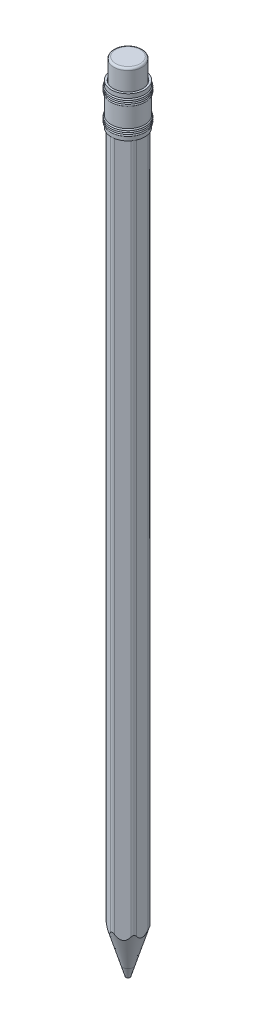
from build123d import *

# Parameters (mm, degrees)
SKETCH1_R           = 1.25
LEAD_DEPTH          = 185
SKETCH2_R           = 1.25
WOODEN_CASING_DEPTH = 185
SKETCH7_R           = 3.5
ERASER_DEPTH        = 10
FILLET1_R           = 0.5
FILLET2_R           = 1
SKETCH10_W          = 1.546794872
SKETCH10_H          = 0.189957265
SKETCH10_W_2        = 2.170940171
TEXT_2_DEPTH        = 0.1


with BuildPart() as part:
    # Sketch1 → lead (new body)
    with BuildSketch(Plane(origin=(0, 0, 0), x_dir=(1, 0, 0), z_dir=(0, 1, 0))):
        Circle(SKETCH1_R)
    extrude(amount=LEAD_DEPTH)


with BuildPart() as body_2:
    # Sketch2 → wooden casing (new body)
    with BuildSketch(Plane(origin=(0, 185, 0), x_dir=(1, 0, 0), z_dir=(0, 1, 0))):
        Polygon((3.5, 2.020725942), (0, 4.041451884), (-3.5, 2.020725942), (-3.5, -2.020725942), (0, -4.041451884), (3.5, -2.020725942), align=None)
        Circle(SKETCH2_R, mode=Mode.SUBTRACT)
    extrude(amount=-WOODEN_CASING_DEPTH)

    # Fillet2
    fillet2_edges = [body_2.edges().sort_by_distance(p)[0] for p in [
        (3.5, 92.5, 2.020725942),
        (0, 92.5, 4.041451884),
        (-3.5, 92.5, 2.020725942),
        (-3.5, 92.5, -2.020725942),
        (0, 92.5, -4.041451884),
        (3.5, 92.5, -2.020725942),
    ]]
    fillet(fillet2_edges, radius=FILLET2_R)

    # Sketch10 → text 2 (cut)
    with BuildSketch(Plane(origin=(-1.75, 0, -3.031088913), x_dir=(-0.866025404, 0, 0.5), z_dir=(-0.5, 0, -0.866025404))):
        with BuildLine():
            Line((-0.603419199, 151.264331842), (-0.603419199, 151.454289107))
            Line((-0.603419199, 151.454289107), (-0.317211266, 151.454289107))
            add(Edge.make_bspline(
                [(-0.317211266, 151.454289107), (-0.342978502, 151.47452059), (-0.393210927, 151.513961235), (-0.459049624, 151.580910418), (-0.513452039, 151.652841151), (-0.557314607, 151.729299821), (-0.589706716, 151.810771863), (-0.613813499, 151.896092609), (-0.627976406, 151.986233983), (-0.629684726, 152.04785591), (-0.630555951, 152.07928243)],
                knots=[0, 0, 0, 0, 9.8212e-05, 0.00019146, 0.000280758, 0.000368114, 0.00045504, 0.000543104, 0.000633658, 0.000727904, 0.000727904, 0.000727904, 0.000727904], degree=3))
            add(Edge.make_bspline(
                [(-0.630555951, 152.07928243), (-0.62976179, 152.106733542), (-0.62819209, 152.160992108), (-0.617564576, 152.240858918), (-0.599350543, 152.317769745), (-0.573103323, 152.391289473), (-0.540654539, 152.462205708), (-0.499701855, 152.529468597), (-0.452284778, 152.594125842), (-0.397715811, 152.654551347), (-0.338673954, 152.710383793), (-0.275160466, 152.758671722), (-0.209264044, 152.800322826), (-0.139963112, 152.8339901), (-0.067803388, 152.860362767), (0.007506669, 152.879119263), (0.085687833, 152.890281743), (0.13884805, 152.891779406), (0.16573812, 152.89253697)],
                knots=[0, 0, 0, 0, 8.2347e-05, 0.000162763, 0.000241232, 0.000319013, 0.000396602, 0.000474774, 0.00055483, 0.000636805, 0.0007187, 0.000798249, 0.000875779, 0.000952201, 0.001028927, 0.00110585, 0.001184643, 0.001265296, 0.001265296, 0.001265296, 0.001265296], degree=3))
            add(Edge.make_bspline(
                [(0.16573812, 152.89253697), (0.193195706, 152.891795843), (0.247346029, 152.890334234), (0.326864417, 152.878997969), (0.403359162, 152.860881192), (0.476703031, 152.834841244), (0.546845525, 152.801191391), (0.613736059, 152.760246252), (0.677353204, 152.71193396), (0.736833291, 152.656718516), (0.791624304, 152.596815074), (0.83954447, 152.532784402), (0.879786159, 152.465620194), (0.913400615, 152.395666074), (0.938735412, 152.322323188), (0.957009987, 152.24593373), (0.96827942, 152.166539289), (0.969762382, 152.112533354), (0.970512425, 152.085218594)],
                knots=[0, 0, 0, 0, 8.2347e-05, 0.0001624, 0.000240457, 0.000317838, 0.000395405, 0.000473434, 0.000552725, 0.000634643, 0.000716587, 0.000795962, 0.000874133, 0.000951135, 0.001028375, 0.001106433, 0.001186486, 0.001268409, 0.001268409, 0.001268409, 0.001268409], degree=3))
            add(Edge.make_bspline(
                [(0.970512425, 152.085218594), (0.969668335, 152.054491619), (0.968001643, 151.993819865), (0.953208674, 151.904859147), (0.92891304, 151.819628908), (0.894840696, 151.738379567), (0.851080577, 151.660884823), (0.797812227, 151.587450252), (0.735044883, 151.517712311), (0.687431544, 151.475736367), (0.663103905, 151.454289107)],
                knots=[0, 0, 0, 0, 9.2129e-05, 0.000181912, 0.000269684, 0.000357487, 0.00044558, 0.000536079, 0.000629147, 0.00072638, 0.00072638, 0.00072638, 0.00072638], degree=3))
            Line((0.663103905, 151.454289107), (1.513247468, 151.454289107))
            Line((1.513247468, 151.454289107), (1.513247468, 151.264331842))
            Line((1.513247468, 151.264331842), (-0.603419199, 151.264331842))
        make_face()
        with BuildLine():
            add(Edge.make_bspline(
                [(-0.440598686, 152.077586383), (-0.440211482, 152.056069219), (-0.439449178, 152.013707469), (-0.430393504, 151.951615222), (-0.417247346, 151.891807035), (-0.397343483, 151.834885665), (-0.37291182, 151.78030553), (-0.342382222, 151.728487011), (-0.306306962, 151.679466482), (-0.265377073, 151.633367278), (-0.220277142, 151.591721382), (-0.172145467, 151.554853325), (-0.121043002, 151.523885098), (-0.067445759, 151.498181495), (-0.01093361, 151.47862151), (0.048171593, 151.464738765), (0.109934543, 151.456011837), (0.151999366, 151.45486948), (0.173370331, 151.454289107)],
                knots=[0, 0, 0, 0, 6.45e-05, 0.000126984, 0.000187876, 0.000247949, 0.000307534, 0.00036702, 0.000427996, 0.000489864, 0.000551674, 0.000611885, 0.000671442, 0.000730615, 0.000789886, 0.000850462, 0.000912526, 0.00097662, 0.00097662, 0.00097662, 0.00097662], degree=3))
            add(Edge.make_bspline(
                [(0.173370331, 151.454289107), (0.201423023, 151.455255241), (0.256380623, 151.457147979), (0.336566282, 151.472388616), (0.412378509, 151.497470682), (0.483323938, 151.532932549), (0.548962684, 151.577229332), (0.607053567, 151.631569179), (0.658357544, 151.693931665), (0.701570104, 151.764142098), (0.736481279, 151.839477957), (0.762264157, 151.917796425), (0.777567444, 151.998547898), (0.779553862, 152.053070921), (0.78055516, 152.080554465)],
                knots=[0, 0, 0, 0, 8.4108e-05, 0.000164775, 0.000243885, 0.000322959, 0.00040199, 0.0004806, 0.000560733, 0.000643567, 0.000727228, 0.000809289, 0.000890373, 0.000972788, 0.000972788, 0.000972788, 0.000972788], degree=3))
            add(Edge.make_bspline(
                [(0.78055516, 152.080554465), (0.779613895, 152.107487969), (0.777745654, 152.160946134), (0.76157582, 152.239661272), (0.736872761, 152.316156213), (0.700859284, 152.388843366), (0.656695679, 152.457049385), (0.603754687, 152.518838067), (0.54197393, 152.572366401), (0.473639536, 152.618426198), (0.400430729, 152.65524914), (0.324821026, 152.683220316), (0.246824071, 152.699155721), (0.194214579, 152.701436884), (0.167858178, 152.702579706)],
                knots=[0, 0, 0, 0, 8.0723e-05, 0.00016022, 0.000240135, 0.000321297, 0.000402798, 0.000483374, 0.000564505, 0.000647296, 0.000729973, 0.000809779, 0.000888527, 0.000967586, 0.000967586, 0.000967586, 0.000967586], degree=3))
            add(Edge.make_bspline(
                [(0.167858178, 152.702579706), (0.141336803, 152.701699341), (0.088500682, 152.69994547), (0.010623041, 152.68269022), (-0.065483072, 152.656711401), (-0.137760663, 152.619065176), (-0.205587365, 152.573718404), (-0.266254431, 152.520087106), (-0.318368027, 152.458599723), (-0.362566644, 152.390923074), (-0.397070688, 152.317591099), (-0.422446265, 152.240628362), (-0.437658162, 152.160160018), (-0.439609889, 152.105353044), (-0.440598686, 152.077586383)],
                knots=[0, 0, 0, 0, 7.9453e-05, 0.000158288, 0.000238209, 0.00032013, 0.000401981, 0.000482476, 0.000562178, 0.000643092, 0.000724269, 0.000804586, 0.00088567, 0.000968932, 0.000968932, 0.000968932, 0.000968932], degree=3))
        make_face(mode=Mode.SUBTRACT)
        with BuildLine():
            Line((0.454914135, 154.541942686), (0.543532591, 154.710699364))
            add(Edge.make_bspline(
                [(0.543532591, 154.710699364), (0.56738076, 154.697244463), (0.613779854, 154.671066554), (0.677530207, 154.626231368), (0.734539621, 154.578800819), (0.783895211, 154.527331784), (0.827482326, 154.473375243), (0.86507865, 154.415906394), (0.897362557, 154.35539432), (0.923816206, 154.29117251), (0.944612927, 154.223317896), (0.959971447, 154.151436736), (0.96887793, 154.075189636), (0.969958909, 154.022975726), (0.970512425, 153.996239561)],
                knots=[0, 0, 0, 0, 8.2102e-05, 0.000159738, 0.000233463, 0.000304231, 0.000373298, 0.000441273, 0.000509938, 0.000578758, 0.000649305, 0.000722571, 0.000798989, 0.000879183, 0.000879183, 0.000879183, 0.000879183], degree=3))
            add(Edge.make_bspline(
                [(0.970512425, 153.996239561), (0.969818657, 153.966520365), (0.968465317, 153.908546824), (0.95679797, 153.8241585), (0.937764685, 153.744705235), (0.911176004, 153.670191482), (0.876446133, 153.600799771), (0.834137352, 153.536391992), (0.784466711, 153.476630156), (0.727005075, 153.423394765), (0.665509145, 153.375477401), (0.6014403, 153.333166093), (0.535020419, 153.297957019), (0.466644684, 153.26887887), (0.396468473, 153.24594172), (0.324089878, 153.229642228), (0.249795901, 153.220333038), (0.199542843, 153.218900106), (0.174218355, 153.218177996)],
                knots=[0, 0, 0, 0, 8.9124e-05, 0.000173856, 0.000254997, 0.000333861, 0.000410659, 0.000487218, 0.00056458, 0.00064317, 0.000721712, 0.000798272, 0.000873197, 0.000946912, 0.001020928, 0.001094375, 0.001169161, 0.001245135, 0.001245135, 0.001245135, 0.001245135], degree=3))
            add(Edge.make_bspline(
                [(0.174218355, 153.218177996), (0.150454338, 153.218818524), (0.103357196, 153.220087967), (0.033648985, 153.228089443), (-0.034101555, 153.242270078), (-0.099950721, 153.261729093), (-0.163788259, 153.286857703), (-0.225653022, 153.317599093), (-0.285479178, 153.35400115), (-0.323218216, 153.382106053), (-0.34222796, 153.396262932)],
                knots=[0, 0, 0, 0, 7.1296e-05, 0.000141299, 0.000210153, 0.000278708, 0.000347053, 0.000415697, 0.000485726, 0.000556803, 0.000556803, 0.000556803, 0.000556803], degree=3))
            add(Edge.make_bspline(
                [(-0.34222796, 153.396262932), (-0.365167582, 153.415405472), (-0.410246472, 153.453022677), (-0.468938508, 153.517306908), (-0.519144528, 153.585977489), (-0.560102698, 153.659725164), (-0.591606006, 153.738425709), (-0.614013893, 153.821673192), (-0.627957104, 153.909697707), (-0.629676498, 153.970039475), (-0.630555951, 154.000903691)],
                knots=[0, 0, 0, 0, 8.9548e-05, 0.000175971, 0.000260359, 0.00034425, 0.000428342, 0.000514024, 0.000602418, 0.00069497, 0.00069497, 0.00069497, 0.00069497], degree=3))
            add(Edge.make_bspline(
                [(-0.630555951, 154.000903691), (-0.629741175, 154.032623828), (-0.62814277, 154.094851507), (-0.613191755, 154.185559449), (-0.589770091, 154.271557745), (-0.555645838, 154.352136694), (-0.513346496, 154.428537899), (-0.459882109, 154.499002995), (-0.39799867, 154.565466295), (-0.350358063, 154.604111721), (-0.326115513, 154.623776954)],
                knots=[0, 0, 0, 0, 9.5093e-05, 0.000186551, 0.000275023, 0.00036188, 0.000448449, 0.000536305, 0.000626592, 0.000720137, 0.000720137, 0.000720137, 0.000720137], degree=3))
            add(Edge.make_bspline(
                [(-0.326115513, 154.623776954), (-0.307849538, 154.637158484), (-0.27143917, 154.663832471), (-0.212068995, 154.697243812), (-0.14995354, 154.726246618), (-0.084088741, 154.749428933), (-0.015254995, 154.76820044), (0.057039782, 154.781781469), (0.132774062, 154.789745953), (0.184376312, 154.791311498), (0.210683365, 154.79210962)],
                knots=[0, 0, 0, 0, 6.7875e-05, 0.000135298, 0.000203974, 0.000273311, 0.000344489, 0.000417837, 0.00049374, 0.000572679, 0.000572679, 0.000572679, 0.000572679], degree=3))
            Line((0.210683365, 154.79210962), (0.210683365, 153.408135261))
            add(Edge.make_bspline(
                [(0.210683365, 153.408135261), (0.231064122, 153.409066356), (0.271142059, 153.410897318), (0.329786294, 153.419433619), (0.385650173, 153.432888829), (0.438314679, 153.451799167), (0.488467661, 153.474699593), (0.535737083, 153.502751907), (0.579907641, 153.536219161), (0.621374434, 153.573548513), (0.658301656, 153.615099947), (0.691352968, 153.658813799), (0.719054448, 153.705316097), (0.741539429, 153.754240176), (0.75914182, 153.805506923), (0.771157121, 153.859132488), (0.779204753, 153.915011349), (0.780099598, 153.953102722), (0.78055516, 153.972494903)],
                knots=[0, 0, 0, 0, 6.1177e-05, 0.000120302, 0.000177481, 0.00023327, 0.000287908, 0.000342665, 0.000397786, 0.000453918, 0.000509765, 0.000564293, 0.000618104, 0.000671795, 0.000725564, 0.000780387, 0.000836454, 0.000894599, 0.000894599, 0.000894599, 0.000894599], degree=3))
            add(Edge.make_bspline(
                [(0.78055516, 153.972494903), (0.780190392, 153.99145571), (0.779466622, 154.029077589), (0.772327988, 154.085091064), (0.761013874, 154.140294226), (0.744718108, 154.194138924), (0.725635985, 154.245840439), (0.703176451, 154.293983368), (0.677570039, 154.337931238), (0.64847156, 154.379166527), (0.612760083, 154.418946196), (0.568623819, 154.459032543), (0.515562174, 154.501066957), (0.475890895, 154.527804712), (0.454914135, 154.541942686)],
                knots=[0, 0, 0, 0, 5.6857e-05, 0.000112815, 0.000169113, 0.000225728, 0.000281409, 0.000334331, 0.000384874, 0.000433819, 0.000485476, 0.000544889, 0.0006125, 0.000688365, 0.000688365, 0.000688365, 0.000688365], degree=3))
        make_face()
        with BuildLine():
            add(Edge.make_bspline(
                [(0.0207261, 154.602152355), (-0.00448261, 154.59522779), (-0.052875143, 154.581934875), (-0.119863688, 154.553625302), (-0.179742238, 154.522511482), (-0.231515746, 154.485056565), (-0.277571164, 154.443033584), (-0.317174949, 154.393823658), (-0.353676999, 154.339561078), (-0.384074516, 154.279165041), (-0.409053959, 154.215017268), (-0.427421571, 154.148436247), (-0.438218603, 154.079979657), (-0.439801596, 154.033872484), (-0.440598686, 154.010655961)],
                knots=[0, 0, 0, 0, 7.8342e-05, 0.000150392, 0.000217735, 0.000280334, 0.000341545, 0.000404195, 0.000469345, 0.000537423, 0.000606558, 0.000675579, 0.000744244, 0.000813887, 0.000813887, 0.000813887, 0.000813887], degree=3))
            add(Edge.make_bspline(
                [(-0.440598686, 154.010655961), (-0.440233084, 153.991695566), (-0.439510366, 153.954214851), (-0.432511344, 153.899020376), (-0.421264693, 153.845876722), (-0.404728225, 153.794942522), (-0.384606612, 153.74587991), (-0.359873078, 153.698724338), (-0.329969802, 153.654081999), (-0.307126846, 153.6261806), (-0.295586667, 153.612084914)],
                knots=[0, 0, 0, 0, 5.6857e-05, 0.000112395, 0.000166618, 0.000219586, 0.000272816, 0.000325544, 0.000379051, 0.000433683, 0.000433683, 0.000433683, 0.000433683], degree=3))
            add(Edge.make_bspline(
                [(-0.295586667, 153.612084914), (-0.286459159, 153.601987871), (-0.267987308, 153.581553916), (-0.236144194, 153.554279343), (-0.201787338, 153.52797015), (-0.163417032, 153.504590599), (-0.122145973, 153.482371806), (-0.077673017, 153.462124724), (-0.029810442, 153.443715141), (0.003558332, 153.433380726), (0.0207261, 153.428063813)],
                knots=[0, 0, 0, 0, 4.0793e-05, 8.2556e-05, 0.000125551, 0.000170496, 0.000217162, 0.000266115, 0.000316984, 0.000370889, 0.000370889, 0.000370889, 0.000370889], degree=3))
            Line((0.0207261, 153.428063813), (0.0207261, 154.602152355))
        make_face(mode=Mode.SUBTRACT)
        with BuildLine():
            Line((-0.603419199, 155.17202415), (-0.603419199, 155.361981415))
            Line((-0.603419199, 155.361981415), (-0.324419466, 155.361981415))
            add(Edge.make_bspline(
                [(-0.324419466, 155.361981415), (-0.349762188, 155.382228687), (-0.398863381, 155.421457513), (-0.46289085, 155.487459193), (-0.516620138, 155.556279309), (-0.558924228, 155.629035607), (-0.590918916, 155.704979409), (-0.613990856, 155.783895227), (-0.627833243, 155.866210194), (-0.629641277, 155.922189915), (-0.630555951, 155.950509727)],
                knots=[0, 0, 0, 0, 9.7232e-05, 0.000188386, 0.000275146, 0.000358561, 0.00044007, 0.000521786, 0.000604737, 0.000689668, 0.000689668, 0.000689668, 0.000689668], degree=3))
            add(Edge.make_bspline(
                [(-0.630555951, 155.950509727), (-0.629561726, 155.979147931), (-0.627614813, 156.035227901), (-0.610410434, 156.116572987), (-0.583343217, 156.193011697), (-0.54491073, 156.263417337), (-0.497448, 156.32703464), (-0.442070067, 156.38270618), (-0.378706573, 156.429128597), (-0.31957811, 156.460157833), (-0.267033951, 156.480209158), (-0.222095045, 156.493389038), (-0.172006279, 156.504050987), (-0.116892771, 156.513604791), (-0.056532768, 156.519978157), (0.008929549, 156.525030258), (0.079482882, 156.528643879), (0.128279006, 156.528787629), (0.153441779, 156.528861757)],
                knots=[0, 0, 0, 0, 8.5828e-05, 0.000168069, 0.000248274, 0.000328339, 0.000407714, 0.000485668, 0.000563011, 0.000642478, 0.000685158, 0.000731579, 0.000782813, 0.000838718, 0.000899309, 0.000964805, 0.001035696, 0.001111175, 0.001111175, 0.001111175, 0.001111175], degree=3))
            Line((0.153441779, 156.528861757), (0.943375673, 156.528861757))
            Line((0.943375673, 156.528861757), (0.943375673, 156.338904492))
            Line((0.943375673, 156.338904492), (0.215771506, 156.338904492))
            add(Edge.make_bspline(
                [(0.215771506, 156.338904492), (0.194712188, 156.338788131), (0.154429296, 156.338565551), (0.096754136, 156.337854337), (0.044590127, 156.336180173), (-0.002212648, 156.333730943), (-0.043482886, 156.33030264), (-0.07942949, 156.326632579), (-0.109734052, 156.322181335), (-0.127976721, 156.318212033), (-0.136158248, 156.316431869)],
                knots=[0, 0, 0, 0, 6.3179e-05, 0.000120851, 0.000173032, 0.000219743, 0.000261434, 0.000297255, 0.000328138, 0.000353251, 0.000353251, 0.000353251, 0.000353251], degree=3))
            add(Edge.make_bspline(
                [(-0.136158248, 156.316431869), (-0.160191313, 156.310037849), (-0.206324508, 156.29776407), (-0.268793601, 156.266818393), (-0.322409558, 156.228647232), (-0.366069699, 156.181354038), (-0.400057995, 156.126208991), (-0.423622777, 156.063120416), (-0.438366118, 155.992741248), (-0.439833737, 155.943238516), (-0.440598686, 155.91743681)],
                knots=[0, 0, 0, 0, 7.4444e-05, 0.000142901, 0.000207867, 0.000270875, 0.000334653, 0.000400957, 0.000471973, 0.000549284, 0.000549284, 0.000549284, 0.000549284], degree=3))
            add(Edge.make_bspline(
                [(-0.440598686, 155.91743681), (-0.440314957, 155.90215452), (-0.439753466, 155.871911261), (-0.4339773, 155.827087987), (-0.424846158, 155.783476056), (-0.411389424, 155.741174755), (-0.394872474, 155.700046794), (-0.375002014, 155.659803504), (-0.350540889, 155.621373583), (-0.323194572, 155.584124646), (-0.292913078, 155.549462309), (-0.260953566, 155.517211811), (-0.226920529, 155.48846251), (-0.191360481, 155.462416246), (-0.153785533, 155.439932241), (-0.114558066, 155.420305852), (-0.073626482, 155.403653312), (-0.045217755, 155.395378541), (-0.031003333, 155.391238226)],
                knots=[0, 0, 0, 0, 4.5825e-05, 9.0686e-05, 0.000135344, 0.000179331, 0.00022366, 0.000268222, 0.000313751, 0.000360139, 0.000406729, 0.000451702, 0.000496221, 0.000540239, 0.000583796, 0.00062741, 0.000671739, 0.000716131, 0.000716131, 0.000716131, 0.000716131], degree=3))
            add(Edge.make_bspline(
                [(-0.031003333, 155.391238226), (-0.020568044, 155.388855676), (0.002149035, 155.383668991), (0.039429232, 155.378066973), (0.082554788, 155.372982391), (0.13147538, 155.368726707), (0.186362285, 155.366122955), (0.246981101, 155.363283963), (0.313573544, 155.362250388), (0.359935616, 155.362073583), (0.384104172, 155.361981415)],
                knots=[0, 0, 0, 0, 3.2102e-05, 6.9884e-05, 0.000113011, 0.000162378, 0.000217156, 0.000277843, 0.000344425, 0.000416933, 0.000416933, 0.000416933, 0.000416933], degree=3))
            Line((0.384104172, 155.361981415), (0.943375673, 155.361981415))
            Line((0.943375673, 155.361981415), (0.943375673, 155.17202415))
            Line((0.943375673, 155.17202415), (-0.603419199, 155.17202415))
        make_face()
        with BuildLine():
            Line((-0.268025903, 158.482707911), (-0.169231165, 158.323703504))
            add(Edge.make_bspline(
                [(-0.169231165, 158.323703504), (-0.190898812, 158.306268299), (-0.233547898, 158.27195006), (-0.288587239, 158.212357284), (-0.335859688, 158.148850381), (-0.37438529, 158.080344133), (-0.404152548, 158.006934625), (-0.425216529, 157.928911358), (-0.438342428, 157.846285457), (-0.439834277, 157.789640313), (-0.440598686, 157.760615897)],
                knots=[0, 0, 0, 0, 8.3336e-05, 0.000164034, 0.000242563, 0.000320401, 0.000399139, 0.000479578, 0.000562395, 0.00064942, 0.00064942, 0.00064942, 0.00064942], degree=3))
            add(Edge.make_bspline(
                [(-0.440598686, 157.760615897), (-0.439959548, 157.737417861), (-0.438700783, 157.69172996), (-0.430832533, 157.624658143), (-0.416534747, 157.560769673), (-0.397695835, 157.499664101), (-0.37244685, 157.441776039), (-0.341719045, 157.386953816), (-0.30600783, 157.334711163), (-0.264635738, 157.286561991), (-0.219642258, 157.242517782), (-0.171410262, 157.204357962), (-0.121384423, 157.171134198), (-0.068315512, 157.145065358), (-0.013417613, 157.123732278), (0.044345528, 157.109697738), (0.104233895, 157.100345279), (0.145066414, 157.099275257), (0.16573812, 157.098733552)],
                knots=[0, 0, 0, 0, 6.9601e-05, 0.000137078, 0.0002022, 0.000265765, 0.000328624, 0.000391264, 0.000454069, 0.000518135, 0.000581403, 0.000642656, 0.0007024, 0.000761183, 0.000819694, 0.000878723, 0.000939168, 0.001001145, 0.001001145, 0.001001145, 0.001001145], degree=3))
            add(Edge.make_bspline(
                [(0.16573812, 157.098733552), (0.192808964, 157.099825884), (0.246724424, 157.102001419), (0.326175482, 157.118548052), (0.402849842, 157.146234928), (0.47633299, 157.183638613), (0.54441973, 157.231116423), (0.605492244, 157.286854152), (0.658357708, 157.350911242), (0.702186446, 157.422715685), (0.73742067, 157.500583559), (0.762522733, 157.583671834), (0.777673451, 157.671301708), (0.779582045, 157.731298169), (0.78055516, 157.761887932)],
                knots=[0, 0, 0, 0, 8.1174e-05, 0.000161669, 0.000242272, 0.000325141, 0.000408301, 0.000490531, 0.000572454, 0.000656593, 0.000742182, 0.00082816, 0.00091634, 0.001008068, 0.001008068, 0.001008068, 0.001008068], degree=3))
            add(Edge.make_bspline(
                [(0.78055516, 157.761887932), (0.779769274, 157.789921782), (0.778224798, 157.845015735), (0.765204902, 157.925550236), (0.743890895, 158.002221897), (0.714168268, 158.075027991), (0.675749247, 158.143835482), (0.628360605, 158.208199793), (0.573365614, 158.26940166), (0.530839983, 158.305383165), (0.509187639, 158.323703504)],
                knots=[0, 0, 0, 0, 8.4061e-05, 0.000165203, 0.000244006, 0.000322352, 0.00040056, 0.000479773, 0.000561717, 0.00064672, 0.00064672, 0.00064672, 0.00064672], degree=3))
            Line((0.509187639, 158.323703504), (0.61349453, 158.482707911))
            add(Edge.make_bspline(
                [(0.61349453, 158.482707911), (0.627337969, 158.473281062), (0.654978901, 158.454458654), (0.693952247, 158.422994328), (0.730432503, 158.389055192), (0.764370767, 158.352773652), (0.796579188, 158.314623451), (0.825517998, 158.273301334), (0.852813819, 158.230139712), (0.877374937, 158.184631888), (0.89945257, 158.137248371), (0.918436754, 158.088055834), (0.934747246, 158.037268043), (0.947711737, 157.984825282), (0.95805972, 157.930624163), (0.964926007, 157.87480486), (0.970051534, 157.817386599), (0.970357463, 157.778577726), (0.970512425, 157.75891985)],
                knots=[0, 0, 0, 0, 5.0229e-05, 0.000100291, 0.000150094, 0.000199587, 0.000249262, 0.000299735, 0.000350793, 0.000402399, 0.000454757, 0.000507514, 0.000560481, 0.000614677, 0.000669479, 0.000725911, 0.000783342, 0.000842294, 0.000842294, 0.000842294, 0.000842294], degree=3))
            add(Edge.make_bspline(
                [(0.970512425, 157.75891985), (0.969972518, 157.72891747), (0.968914295, 157.670112587), (0.957310374, 157.584035819), (0.939752034, 157.501800043), (0.914764782, 157.423260742), (0.881766248, 157.348898076), (0.842381322, 157.278092972), (0.795308446, 157.211576093), (0.741665914, 157.149783502), (0.683445631, 157.093274197), (0.620984012, 157.044102215), (0.555661275, 157.002430496), (0.487065678, 156.968102696), (0.415478492, 156.941261559), (0.340462387, 156.922782392), (0.262653836, 156.910859006), (0.209596959, 156.909476951), (0.18269859, 156.908776287)],
                knots=[0, 0, 0, 0, 8.9954e-05, 0.000176311, 0.000260061, 0.000341992, 0.000423059, 0.000503738, 0.000584675, 0.000667044, 0.000748909, 0.000827713, 0.000905111, 0.00098096, 0.001057436, 0.001133947, 0.001212381, 0.001293034, 0.001293034, 0.001293034, 0.001293034], degree=3))
            add(Edge.make_bspline(
                [(0.18269859, 156.908776287), (0.164447822, 156.909042996), (0.128144033, 156.909573526), (0.074262731, 156.915658597), (0.021098992, 156.923519578), (-0.030673296, 156.936839905), (-0.081839352, 156.95222543), (-0.131782466, 156.971865394), (-0.18073472, 156.994904038), (-0.228570014, 157.021061168), (-0.274501402, 157.050506266), (-0.317895285, 157.083091583), (-0.359272953, 157.117589825), (-0.397205894, 157.155614902), (-0.433211114, 157.195553169), (-0.466326742, 157.23853455), (-0.496650103, 157.284312518), (-0.524741908, 157.332199575), (-0.549754518, 157.382167852), (-0.571304143, 157.433915315), (-0.589720701, 157.487130147), (-0.604300857, 157.541897472), (-0.616527584, 157.597853777), (-0.624218853, 157.655440015), (-0.629653409, 157.714435882), (-0.630252602, 157.754384049), (-0.630555951, 157.774608285)],
                knots=[0, 0, 0, 0, 5.4724e-05, 0.000108855, 0.00016253, 0.000215801, 0.000269046, 0.000322747, 0.000376616, 0.000431268, 0.000486195, 0.000540129, 0.000593985, 0.000647654, 0.000701107, 0.000755216, 0.000810253, 0.00086574, 0.000921679, 0.000977746, 0.001033796, 0.001090471, 0.001147686, 0.001205492, 0.001264649, 0.001325306, 0.001325306, 0.001325306, 0.001325306], degree=3))
            add(Edge.make_bspline(
                [(-0.630555951, 157.774608285), (-0.629998484, 157.79993581), (-0.628886337, 157.850464262), (-0.61952458, 157.925418412), (-0.605414829, 157.999270788), (-0.584494532, 158.070715129), (-0.559219998, 158.138923383), (-0.530666918, 158.20260212), (-0.498212122, 158.260789662), (-0.462054308, 158.313999258), (-0.420864787, 158.362216163), (-0.375062815, 158.406676191), (-0.32431871, 158.447672272), (-0.286945032, 158.470932982), (-0.268025903, 158.482707911)],
                knots=[0, 0, 0, 0, 7.5956e-05, 0.000151533, 0.00022629, 0.000301306, 0.000374556, 0.000444388, 0.000510447, 0.000574191, 0.000637061, 0.00070033, 0.00076549, 0.00083229, 0.00083229, 0.00083229, 0.00083229], degree=3))
        make_face()
        with BuildLine():
            add(Edge.make_bspline(
                [(-1.25470125, 158.929616297), (-1.254154453, 158.941403903), (-1.25308372, 158.964486298), (-1.243914636, 158.997865083), (-1.228372445, 159.02825861), (-1.207520448, 159.055217524), (-1.182997689, 159.078350808), (-1.154416056, 159.094546762), (-1.123537736, 159.104956163), (-1.101999087, 159.106213194), (-1.091032714, 159.10685321)],
                knots=[0, 0, 0, 0, 3.5318e-05, 6.9159e-05, 0.000102913, 0.00013709, 0.000171003, 0.000203295, 0.00023494, 0.000267764, 0.000267764, 0.000267764, 0.000267764], degree=3))
            add(Edge.make_bspline(
                [(-1.091032714, 159.10685321), (-1.080351014, 159.106198761), (-1.059234558, 159.104904992), (-1.028891553, 159.094554802), (-1.000707058, 159.078212782), (-0.976231914, 159.055232358), (-0.955391444, 159.028254679), (-0.939846197, 158.997866128), (-0.930677924, 158.964486023), (-0.929607078, 158.94140381), (-0.929060224, 158.929616297)],
                knots=[0, 0, 0, 0, 3.1981e-05, 6.3223e-05, 9.5148e-05, 0.000129061, 0.000163238, 0.000196992, 0.000230833, 0.000266151, 0.000266151, 0.000266151, 0.000266151], degree=3))
            add(Edge.make_bspline(
                [(-0.929060224, 158.929616297), (-0.929586198, 158.917963579), (-0.930609937, 158.895283084), (-0.940026091, 158.862404089), (-0.955396763, 158.832269717), (-0.976095456, 158.805258224), (-1.00085737, 158.782742822), (-1.028874353, 158.766354787), (-1.059238937, 158.7560285), (-1.080352485, 158.754731511), (-1.091032714, 158.754075432)],
                knots=[0, 0, 0, 0, 3.4895e-05, 6.7919e-05, 0.000101673, 0.00013585, 0.000169478, 0.000201403, 0.000232645, 0.000264626, 0.000264626, 0.000264626, 0.000264626], degree=3))
            add(Edge.make_bspline(
                [(-1.091032714, 158.754075432), (-1.101997561, 158.754717137), (-1.123533213, 158.755977485), (-1.154433542, 158.766362527), (-1.182846164, 158.782606316), (-1.207656824, 158.805273133), (-1.228367158, 158.832265749), (-1.243734752, 158.862405114), (-1.253151704, 158.895282813), (-1.254175333, 158.917963487), (-1.25470125, 158.929616297)],
                knots=[0, 0, 0, 0, 3.2825e-05, 6.447e-05, 9.6761e-05, 0.00013039, 0.000164567, 0.00019832, 0.000231344, 0.00026624, 0.00026624, 0.00026624, 0.00026624], degree=3))
        make_face()
        with Locations((0.169978237, 158.93046432)):
            Rectangle(SKETCH10_W, SKETCH10_H)
        with Locations((-0.142094412, 159.527472868)):
            Rectangle(SKETCH10_W_2, SKETCH10_H)
        with BuildLine():
            Line((-0.522008942, 161.006425859), (-0.522008942, 160.816468594))
            add(Edge.make_bspline(
                [(-0.522008942, 160.816468594), (-0.547209908, 160.817706635), (-0.596703933, 160.820138112), (-0.668866486, 160.831524745), (-0.737842484, 160.847817561), (-0.803078098, 160.870853821), (-0.865150139, 160.899462856), (-0.923812053, 160.933771015), (-0.978840058, 160.974407296), (-1.029724025, 161.020494226), (-1.076404127, 161.070549546), (-1.116714679, 161.124558376), (-1.150773461, 161.181312273), (-1.179246402, 161.240639052), (-1.200618595, 161.30320806), (-1.216476444, 161.368451503), (-1.226017377, 161.436656028), (-1.227042923, 161.483125946), (-1.227564498, 161.506759727)],
                knots=[0, 0, 0, 0, 7.5645e-05, 0.000148566, 0.000218806, 0.000288002, 0.000355729, 0.000423578, 0.000491507, 0.00056056, 0.000629272, 0.00069652, 0.00076233, 0.000827574, 0.000893548, 0.000960292, 0.001028772, 0.001099644, 0.001099644, 0.001099644, 0.001099644], degree=3))
            add(Edge.make_bspline(
                [(-1.227564498, 161.506759727), (-1.227025555, 161.529970957), (-1.225966552, 161.575580196), (-1.216735362, 161.642118404), (-1.202589386, 161.705611811), (-1.181627278, 161.765340849), (-1.155324418, 161.821918504), (-1.122613366, 161.874644253), (-1.085041898, 161.924793057), (-1.04072451, 161.969903702), (-0.993437744, 162.011343271), (-0.942935876, 162.047061674), (-0.890715389, 162.077822644), (-0.836368366, 162.102999537), (-0.779717826, 162.122084742), (-0.721306898, 162.136225049), (-0.660461479, 162.144308413), (-0.619272044, 162.145542189), (-0.598331058, 162.146169449)],
                knots=[0, 0, 0, 0, 6.9601e-05, 0.000136764, 0.000201152, 0.000264445, 0.000326281, 0.000387948, 0.000450279, 0.000513853, 0.000577275, 0.000638691, 0.000699123, 0.000758884, 0.000818017, 0.00087818, 0.000938926, 0.00100175, 0.00100175, 0.00100175, 0.00100175], degree=3))
            add(Edge.make_bspline(
                [(-0.598331058, 162.146169449), (-0.568850237, 162.145145412), (-0.510405943, 162.143115309), (-0.424520578, 162.125750183), (-0.341310028, 162.098627824), (-0.274338043, 162.065975174), (-0.220378135, 162.033025837), (-0.175928276, 162.003363399), (-0.128080324, 161.968441126), (-0.076640613, 161.928557378), (-0.022282791, 161.883025302), (0.036102188, 161.833027813), (0.097434747, 161.77727371), (0.139353001, 161.738176681), (0.16107399, 161.717917579)],
                knots=[0, 0, 0, 0, 8.8367e-05, 0.000175182, 0.000261801, 0.000350363, 0.00039792, 0.000451428, 0.000510628, 0.000575595, 0.00064666, 0.000723327, 0.000806184, 0.000895292, 0.000895292, 0.000895292, 0.000895292], degree=3))
            Line((0.16107399, 161.717917579), (0.726281656, 161.188326901))
            Line((0.726281656, 161.188326901), (0.726281656, 162.173306201))
            Line((0.726281656, 162.173306201), (0.943375673, 162.173306201))
            Line((0.943375673, 162.173306201), (0.943375673, 160.735058338))
            Line((0.943375673, 160.735058338), (0.067367393, 161.55594509))
            add(Edge.make_bspline(
                [(0.067367393, 161.55594509), (0.046504131, 161.575931193), (0.006430076, 161.614320407), (-0.052076381, 161.668617489), (-0.106353484, 161.717384877), (-0.156298683, 161.760938253), (-0.202642536, 161.798332801), (-0.243884094, 161.831517437), (-0.281835595, 161.858106151), (-0.325826347, 161.886962605), (-0.379536654, 161.91491106), (-0.445173694, 161.93892758), (-0.51274208, 161.953571798), (-0.558402836, 161.955328532), (-0.581370588, 161.956212184)],
                knots=[0, 0, 0, 0, 8.6674e-05, 0.000166483, 0.000239444, 0.000305579, 0.000365245, 0.00041809, 0.000464325, 0.000504196, 0.000575883, 0.000645364, 0.000713388, 0.000782236, 0.000782236, 0.000782236, 0.000782236], degree=3))
            add(Edge.make_bspline(
                [(-0.581370588, 161.956212184), (-0.595813148, 161.955827711), (-0.62427666, 161.95506999), (-0.666008714, 161.948382715), (-0.706264578, 161.938276838), (-0.745168076, 161.923795658), (-0.782328066, 161.904681106), (-0.81778978, 161.881413871), (-0.852073107, 161.854568452), (-0.884218196, 161.82351316), (-0.913658735, 161.789397622), (-0.939738539, 161.75335729), (-0.96153362, 161.715226989), (-0.979400402, 161.675167487), (-0.993415989, 161.633290465), (-1.003127607, 161.589514928), (-1.009225109, 161.543961833), (-1.010050108, 161.512856814), (-1.010470481, 161.497007457)],
                knots=[0, 0, 0, 0, 4.3301e-05, 8.5338e-05, 0.000126474, 0.000167664, 0.000209573, 0.000251559, 0.000294735, 0.000340017, 0.00038541, 0.000429771, 0.000473265, 0.00051692, 0.000561168, 0.000605503, 0.000651259, 0.000698795, 0.000698795, 0.000698795, 0.000698795], degree=3))
            add(Edge.make_bspline(
                [(-1.010470481, 161.497007457), (-1.010055119, 161.480450465), (-1.009239418, 161.447935267), (-1.003060889, 161.400297089), (-0.993694236, 161.354538542), (-0.978817946, 161.311342383), (-0.961240871, 161.269773227), (-0.938911091, 161.23071851), (-0.91296339, 161.193529804), (-0.882875973, 161.158818792), (-0.849070586, 161.12711659), (-0.811814715, 161.098870387), (-0.771376573, 161.074352685), (-0.727922126, 161.052931342), (-0.681018731, 161.035543014), (-0.630843541, 161.022253918), (-0.577611418, 161.011739175), (-0.540850934, 161.008226381), (-0.522008942, 161.006425859)],
                knots=[0, 0, 0, 0, 4.9655e-05, 9.7514e-05, 0.000143919, 0.000189508, 0.000234327, 0.000279136, 0.000324189, 0.00037018, 0.000416677, 0.000462979, 0.000510174, 0.00055834, 0.000608116, 0.000659957, 0.000713926, 0.000770677, 0.000770677, 0.000770677, 0.000770677], degree=3))
        make_face()
        with BuildLine():
            Line((0.943375673, 162.498947227), (-1.227564498, 162.498947227))
            Line((-1.227564498, 162.498947227), (-1.227564498, 162.688904492))
            Line((-1.227564498, 162.688904492), (-0.322723419, 162.688904492))
            add(Edge.make_bspline(
                [(-0.322723419, 162.688904492), (-0.347372263, 162.710309083), (-0.395463175, 162.752070324), (-0.458266278, 162.822087511), (-0.511517062, 162.895508974), (-0.555414381, 162.972893253), (-0.588841753, 163.054350408), (-0.613287674, 163.139459826), (-0.628035944, 163.228439074), (-0.62970876, 163.289108289), (-0.630555951, 163.319833979)],
                knots=[0, 0, 0, 0, 9.7859e-05, 0.000190928, 0.000281426, 0.00036952, 0.00045716, 0.000544932, 0.000634715, 0.000726844, 0.000726844, 0.000726844, 0.000726844], degree=3))
            add(Edge.make_bspline(
                [(-0.630555951, 163.319833979), (-0.629805908, 163.347148739), (-0.628322946, 163.401154673), (-0.617053513, 163.480549115), (-0.598778937, 163.556938572), (-0.573444143, 163.630281463), (-0.539829676, 163.700235563), (-0.499588028, 163.767399849), (-0.451667705, 163.831430216), (-0.396877298, 163.891334837), (-0.33739496, 163.946545902), (-0.273785912, 163.994873944), (-0.206974786, 164.035695189), (-0.137185224, 164.069459827), (-0.064132193, 164.095568036), (0.01211268, 164.113555026), (0.091474386, 164.124981073), (0.145487367, 164.126420556), (0.172946319, 164.127152355)],
                knots=[0, 0, 0, 0, 8.1923e-05, 0.000161976, 0.000240033, 0.000317273, 0.000394276, 0.000472447, 0.000551822, 0.000633766, 0.000715684, 0.000794975, 0.000873004, 0.000950189, 0.00102717, 0.001105228, 0.00118486, 0.001267207, 0.001267207, 0.001267207, 0.001267207], degree=3))
            add(Edge.make_bspline(
                [(0.172946319, 164.127152355), (0.199979187, 164.126404603), (0.253283745, 164.124930154), (0.331725329, 164.113668696), (0.407223019, 164.095074526), (0.479581727, 164.068488477), (0.549141389, 164.035066348), (0.615109062, 163.993270481), (0.678632633, 163.945003829), (0.737671686, 163.889165468), (0.792241409, 163.828741557), (0.839658289, 163.764083896), (0.880611024, 163.696821115), (0.913059794, 163.625904852), (0.939307018, 163.552385131), (0.95752105, 163.475474302), (0.968148565, 163.395607493), (0.969718265, 163.341348927), (0.970512425, 163.313897814)],
                knots=[0, 0, 0, 0, 8.1076e-05, 0.000159869, 0.000237204, 0.00031393, 0.000390733, 0.000468264, 0.000547812, 0.000629708, 0.000711682, 0.000791739, 0.00086991, 0.000947499, 0.00102528, 0.00110375, 0.001184166, 0.001266512, 0.001266512, 0.001266512, 0.001266512], degree=3))
            add(Edge.make_bspline(
                [(0.970512425, 163.313897814), (0.969642163, 163.2824707), (0.967935729, 163.220847607), (0.953759218, 163.130714639), (0.929702123, 163.04536319), (0.897153346, 162.964068863), (0.853983909, 162.887165276), (0.798905035, 162.815847634), (0.733596719, 162.748280668), (0.683134846, 162.709077827), (0.65716774, 162.688904492)],
                knots=[0, 0, 0, 0, 9.4246e-05, 0.0001848, 0.000272864, 0.000359791, 0.000446937, 0.000536491, 0.000629443, 0.000727983, 0.000727983, 0.000727983, 0.000727983], degree=3))
            Line((0.65716774, 162.688904492), (0.943375673, 162.688904492))
            Line((0.943375673, 162.688904492), (0.943375673, 162.498947227))
        make_face()
        with BuildLine():
            add(Edge.make_bspline(
                [(0.78055516, 163.312201767), (0.779567209, 163.339969026), (0.77761715, 163.394777179), (0.762393027, 163.475236886), (0.737063391, 163.55223208), (0.70241933, 163.625372306), (0.658867066, 163.693522181), (0.606149889, 163.754371906), (0.545942271, 163.808644146), (0.477745482, 163.853530952), (0.405565237, 163.891255191), (0.329765338, 163.917309236), (0.25216915, 163.93459024), (0.199468988, 163.936323024), (0.172946319, 163.93719509)],
                knots=[0, 0, 0, 0, 8.3262e-05, 0.000164346, 0.000244663, 0.00032584, 0.000406524, 0.000486502, 0.00056668, 0.000648883, 0.000730804, 0.000810325, 0.000888744, 0.000968197, 0.000968197, 0.000968197, 0.000968197], degree=3))
            add(Edge.make_bspline(
                [(0.172946319, 163.93719509), (0.146448349, 163.936053455), (0.093558194, 163.933774741), (0.015151015, 163.917824277), (-0.060799596, 163.889970281), (-0.134083428, 163.853008428), (-0.20242624, 163.807126361), (-0.263803603, 163.753298945), (-0.316756546, 163.69168471), (-0.36089816, 163.623453404), (-0.396917509, 163.550773003), (-0.421619024, 163.474276286), (-0.437789261, 163.395561612), (-0.439657449, 163.342103386), (-0.440598686, 163.31516985)],
                knots=[0, 0, 0, 0, 7.9482e-05, 0.000158646, 0.00023885, 0.000321527, 0.000404318, 0.000485131, 0.000565707, 0.000647207, 0.00072837, 0.000808284, 0.000887782, 0.000968505, 0.000968505, 0.000968505, 0.000968505], degree=3))
            add(Edge.make_bspline(
                [(-0.440598686, 163.31516985), (-0.439657975, 163.287672841), (-0.437790854, 163.233096859), (-0.42159068, 163.152561674), (-0.396766334, 163.073904807), (-0.3611281, 162.998738716), (-0.317513423, 162.928680938), (-0.266281576, 162.865997277), (-0.20778121, 162.81213513), (-0.142488245, 162.767396145), (-0.071554302, 162.732112821), (0.00423288, 162.70699649), (0.08428601, 162.691792669), (0.139099914, 162.689878932), (0.167010155, 162.688904492)],
                knots=[0, 0, 0, 0, 8.2415e-05, 0.000163578, 0.000245509, 0.000329349, 0.000412407, 0.00049254, 0.000571462, 0.000650143, 0.000729217, 0.000808326, 0.000888993, 0.000972679, 0.000972679, 0.000972679, 0.000972679], degree=3))
            add(Edge.make_bspline(
                [(0.167010155, 162.688904492), (0.188381199, 162.689484735), (0.230446177, 162.690626839), (0.292208003, 162.699355612), (0.35131732, 162.713231601), (0.407814494, 162.732816171), (0.461358353, 162.758376298), (0.512157315, 162.789608789), (0.560244881, 162.826318258), (0.60533049, 162.867987685), (0.646264243, 162.914080541), (0.682338487, 162.963102739), (0.712868349, 163.014920823), (0.737299942, 163.069501074), (0.757203824, 163.126422413), (0.770349977, 163.186230609), (0.779405652, 163.248322853), (0.780167956, 163.290684603), (0.78055516, 163.312201767)],
                knots=[0, 0, 0, 0, 6.4095e-05, 0.000126158, 0.000186734, 0.000246005, 0.000305178, 0.000364373, 0.000424584, 0.000486394, 0.000548262, 0.000609239, 0.000668725, 0.00072831, 0.000788382, 0.000849275, 0.000911758, 0.000976258, 0.000976258, 0.000976258, 0.000976258], degree=3))
        make_face(mode=Mode.SUBTRACT)
    extrude(amount=-TEXT_2_DEPTH, mode=Mode.SUBTRACT)


with BuildPart() as body_3:
    # Sketch7 → eraser (new body)
    with BuildSketch(Plane(origin=(0, 185, 0), x_dir=(1, 0, 0), z_dir=(0, 1, 0))):
        Circle(SKETCH7_R)
    extrude(amount=ERASER_DEPTH)

    # Fillet1
    fillet1_edges = [body_3.edges().sort_by_distance(p)[0] for p in [
        (-3.5, 195, 0),
    ]]
    fillet(fillet1_edges, radius=FILLET1_R)


with BuildPart() as body_4:
    # Sketch8 → ferrule (revolve)
    with BuildSketch(Plane.XY):
        with BuildLine():
            Line((-4.1, 190), (-3.6, 190))
            Line((-3.6, 190), (-3.6, 189))
            ThreePointArc((-3.6, 189), (-3.39999997, 188.800000015), (-3.59999997, 188.6))
            ThreePointArc((-3.59999997, 188.6), (-3.39999997, 188.399999985), (-3.6, 188.2))
            ThreePointArc((-3.6, 188.2), (-3.39999997, 188), (-3.6, 187.8))
            ThreePointArc((-3.6, 187.8), (-3.39999997, 187.6), (-3.6, 187.4))
            Line((-3.6, 187.4), (-3.6, 182.6))
            ThreePointArc((-3.6, 182.6), (-3.39999997, 182.4), (-3.6, 182.2))
            ThreePointArc((-3.6, 182.2), (-3.39999997, 182), (-3.6, 181.8))
            ThreePointArc((-3.6, 181.8), (-3.39999997, 181.600000015), (-3.59999997, 181.4))
            ThreePointArc((-3.59999997, 181.4), (-3.39999997, 181.199999985), (-3.6, 181))
            Line((-3.6, 181), (-3.6, 180))
            Line((-3.6, 180), (-4.1, 180))
            Line((-4.1, 180), (-4.1, 181))
            ThreePointArc((-4.1, 181), (-4.30000003, 181.199999985), (-4.10000003, 181.4))
            ThreePointArc((-4.10000003, 181.4), (-4.30000003, 181.600000015), (-4.1, 181.8))
            ThreePointArc((-4.1, 181.8), (-4.30000003, 182), (-4.1, 182.2))
            ThreePointArc((-4.1, 182.2), (-4.30000003, 182.4), (-4.1, 182.6))
            Line((-4.1, 182.6), (-4.1, 187.4))
            ThreePointArc((-4.1, 187.4), (-4.30000003, 187.6), (-4.1, 187.8))
            ThreePointArc((-4.1, 187.8), (-4.30000003, 188), (-4.1, 188.2))
            ThreePointArc((-4.1, 188.2), (-4.30000003, 188.399999985), (-4.10000003, 188.6))
            ThreePointArc((-4.10000003, 188.6), (-4.30000003, 188.800000015), (-4.1, 189))
            Line((-4.1, 189), (-4.1, 190))
        make_face()
    revolve(axis=Axis((0, 195, 0), (0, -1, 0)))


with BuildPart() as cut_revolve1_tool:
    # Sketch14 → Cut-Revolve1 (revolve)
    with BuildSketch(Plane.XY):
        Polygon((0.5, 0), (5, 0), (5, 15), align=None)
    revolve(axis=Axis((0, 0, 0), (0, 1, 0)))


with BuildPart() as part_1:
    add(part.part)

    # Cut-Revolve1: cut by cut_revolve1_tool
    add(cut_revolve1_tool.part, mode=Mode.SUBTRACT)


with BuildPart() as body_2_1:
    add(body_2.part)

    # Cut-Revolve1: cut by cut_revolve1_tool
    add(cut_revolve1_tool.part, mode=Mode.SUBTRACT)


solid = Compound([body_3.part, body_4.part, part_1.part, body_2_1.part])
